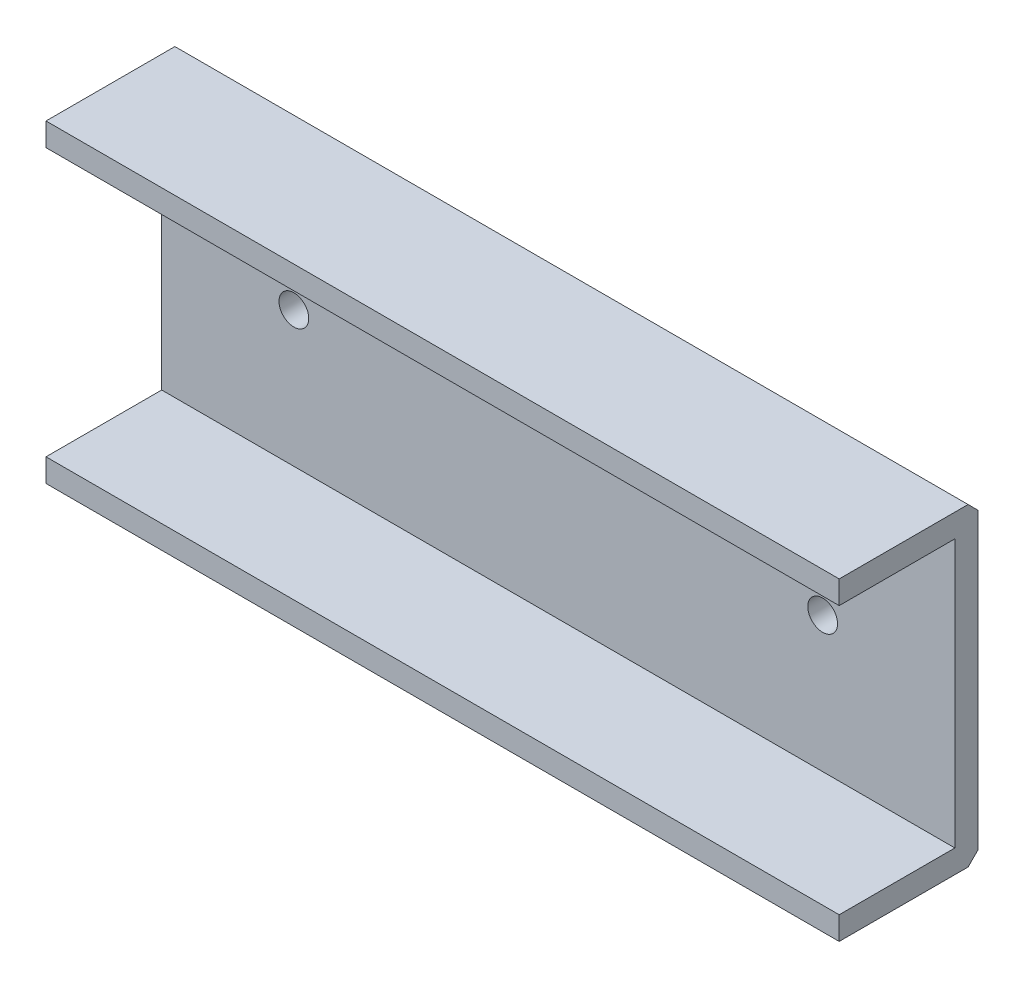
from build123d import *

# Parameters (mm, degrees)
SALIENTE_EXTRUIR1_DEPTH = 60
CHAFL_N1_SIZE           = 1.5
CROQUIS3_R              = 2.25
CORTAR_EXTRUIR2_DEPTH   = 4.5


with BuildPart() as part:
    # Croquis1 → Saliente-Extruir1 (new body, symmetric)
    with BuildSketch(Plane(origin=(0, 0, 0), x_dir=(0, 0, -1), z_dir=(1, 0, 0))):
        Polygon((0, -23.75), (0, 23.75), (-21, 23.75), (-21, 20.25), (-3.5, 20.25), (-3.5, -20.25), (-21, -20.25), (-21, -23.75), align=None)
    extrude(amount=SALIENTE_EXTRUIR1_DEPTH, both=True)

    # Chaflán1
    chafl_n1_edges = [part.edges().sort_by_distance(p)[0] for p in [
        (0, 23.75, 0),
        (0, -23.75, 0),
    ]]
    chamfer(chafl_n1_edges, length=CHAFL_N1_SIZE)

    # Croquis3 → Cortar-Extruir2 (cut, through all)
    with BuildSketch(Plane.XY.offset(3.5)):
        with Locations((-40, 0.25)):
            Circle(CROQUIS3_R)
        with Locations((40, 0.25)):
            Circle(CROQUIS3_R)
    extrude(amount=-CORTAR_EXTRUIR2_DEPTH, mode=Mode.SUBTRACT)


solid = part.part
